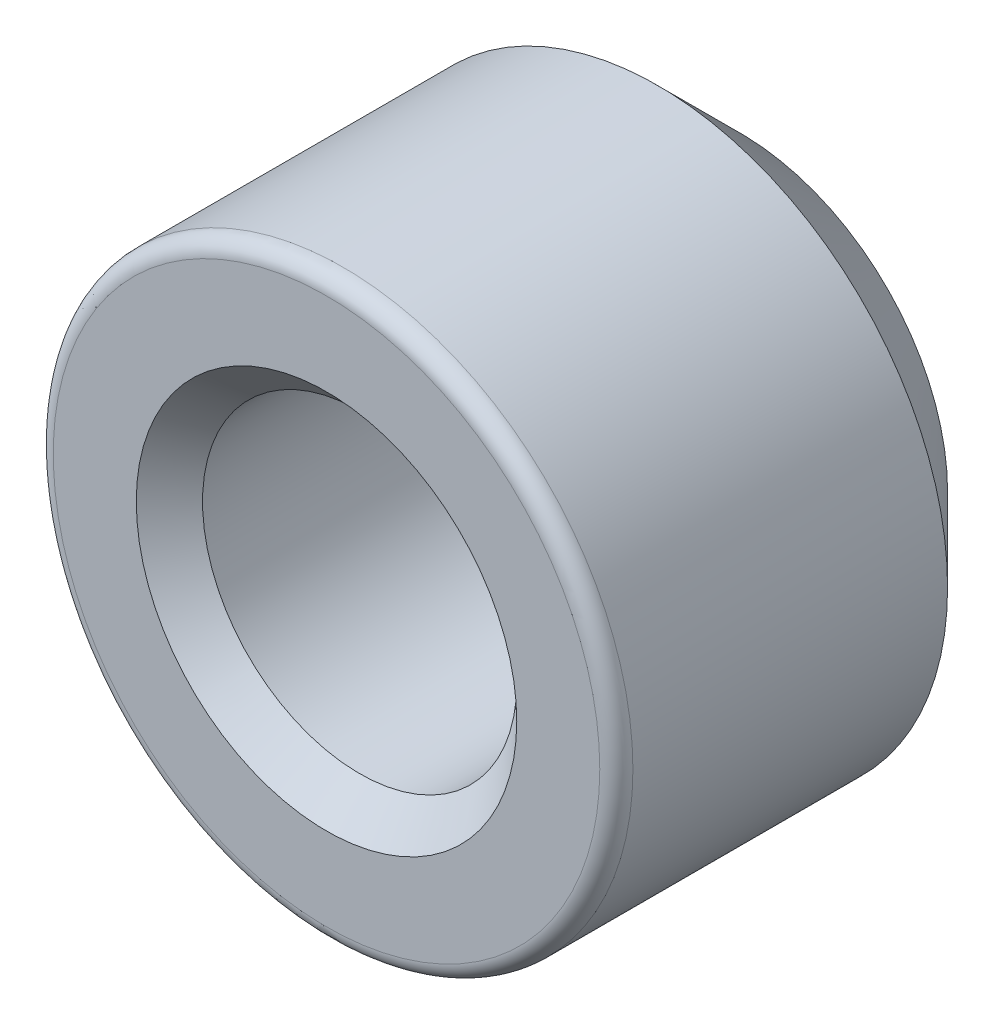
from build123d import *

# Parameters (mm, degrees)
SKETCH1_R                        = 17.5
BOSS_EXTRUDE1_DEPTH              = 12.5
F_1_2_14_NPSM_TAPPED_HOLE1_D     = 18.9738
F_1_2_14_NPSM_TAPPED_HOLE1_DEPTH = 47.24908
F_1_2_14_NPSM_TAPPED_HOLE1_TIP   = 5.700304607
CHAMFER1_SIZE                    = 5
CHAMFER2_SIZE                    = 2
FILLET1_R                        = 1


with BuildPart() as part:
    # Sketch1 → Boss-Extrude1 (new body, symmetric)
    with BuildSketch(Plane.XY):
        Circle(SKETCH1_R)
    extrude(amount=BOSS_EXTRUDE1_DEPTH, both=True)

    # 1/2-14 NPSM Tapped Hole1
    with Locations(Plane.XY.offset(12.5)):
        with Locations((0, 0)):
            Hole(F_1_2_14_NPSM_TAPPED_HOLE1_D / 2, depth=F_1_2_14_NPSM_TAPPED_HOLE1_DEPTH)
            with Locations((0, 0, -(F_1_2_14_NPSM_TAPPED_HOLE1_DEPTH + F_1_2_14_NPSM_TAPPED_HOLE1_TIP / 2))):  # 118° drill point
                Cone(0, F_1_2_14_NPSM_TAPPED_HOLE1_D / 2, F_1_2_14_NPSM_TAPPED_HOLE1_TIP, mode=Mode.SUBTRACT)

    # Chamfer1
    chamfer1_edges = [part.edges().sort_by_distance(p)[0] for p in [
        (-17.5, 0, -12.5),
    ]]
    chamfer(chamfer1_edges, length=CHAMFER1_SIZE)

    # Chamfer2
    chamfer2_edges = [part.edges().sort_by_distance(p)[0] for p in [
        (9.4869, 0, 12.5),
    ]]
    chamfer(chamfer2_edges, length=CHAMFER2_SIZE)

    # Fillet1
    fillet1_edges = [part.edges().sort_by_distance(p)[0] for p in [
        (-17.5, 0, 12.5),
    ]]
    fillet(fillet1_edges, radius=FILLET1_R)


solid = part.part
